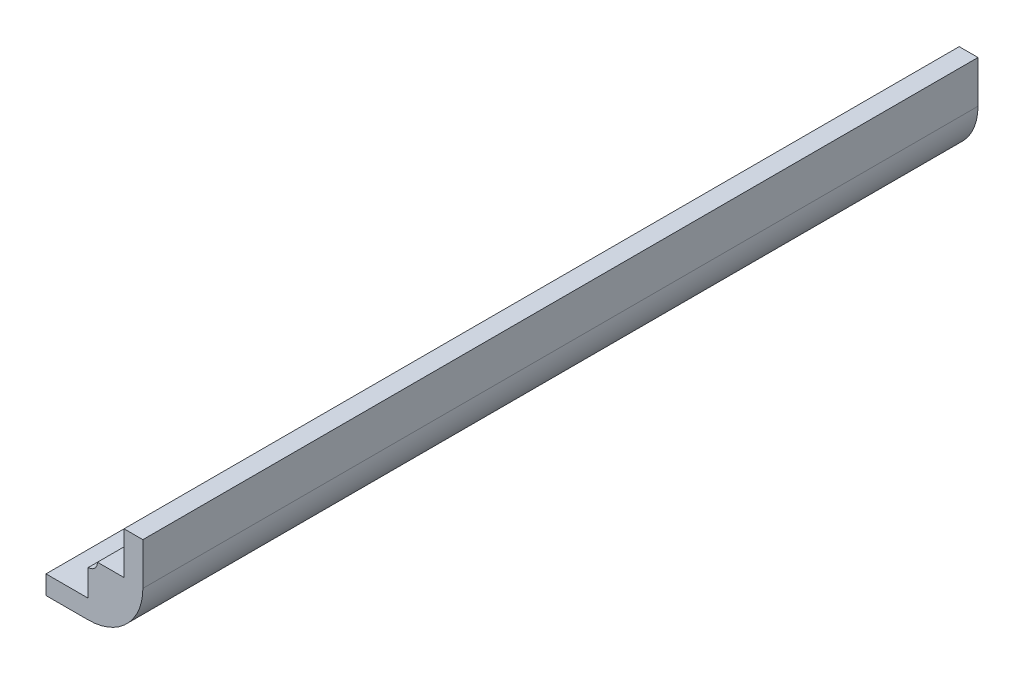
from build123d import *

# Parameters (mm, degrees)
SKETCH7_W           = 4.7625
SKETCH7_H           = 2.12122512
BOSS_EXTRUDE2_DEPTH = 47.09795
SKETCH8_W           = 2.12122512
SKETCH8_H           = 4.7625
BOSS_EXTRUDE3_DEPTH = 47.09795
BOSS_EXTRUDE4_DEPTH = 47.09795


with BuildPart() as part:
    # Sketch7 → Boss-Extrude2 (new, symmetric)
    with BuildSketch(Plane.XY):
        with Locations((-4.92125, -2.560612608)):
            Rectangle(SKETCH7_W, SKETCH7_H)
    extrude(amount=BOSS_EXTRUDE2_DEPTH, both=True)



with BuildPart() as body_2:
    # Sketch8 → Boss-Extrude3 (new, symmetric)
    with BuildSketch(Plane.XY):
        with Locations((2.560612608, 4.92125)):
            Rectangle(SKETCH8_W, SKETCH8_H)
    extrude(amount=BOSS_EXTRUDE3_DEPTH, both=True)


with BuildPart() as part_1:
    add(part.part)

    add(body_2.part)  # Boss-Extrude4 merges body 2
    # Sketch11 → Boss-Extrude4 (add, symmetric)
    with BuildSketch(Plane.XY):
        with BuildLine():
            Line((-2.54, -1.500000048), (-7.3025, -1.500000048))
            Line((-7.3025, -1.500000048), (-7.3025, -3.621225168))
            Line((-7.3025, -3.621225168), (-2.54, -3.621225168))
            ThreePointArc((-2.54, -3.621225168), (1.816644097, -1.816644097), (3.621225168, 2.54))
            Line((3.621225168, 2.54), (3.621225168, 7.3025))
            Line((3.621225168, 7.3025), (1.500000048, 7.3025))
            Line((1.500000048, 7.3025), (1.500000048, 2.54))
            Line((1.500000048, 2.54), (-1.500000048, 2.54))
            ThreePointArc((-1.500000048, 2.54), (-1.804608982, 1.804608982), (-2.54, 1.500000048))
            Line((-2.54, 1.500000048), (-2.54, -1.500000048))
        make_face()
    extrude(amount=BOSS_EXTRUDE4_DEPTH, both=True)


solid = part_1.part
